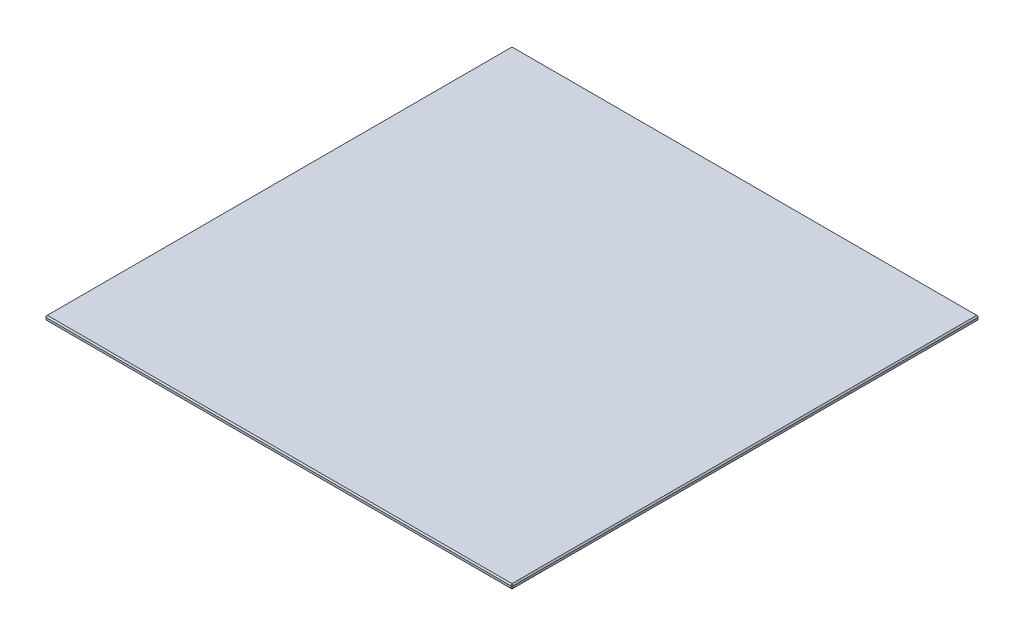
from build123d import *

# Parameters (mm, degrees)
SKETCH1_W           = 300
SKETCH1_H           = 300
BOSS_EXTRUDE1_DEPTH = 3
CHAMFER1_SIZE       = 0.8


with BuildPart() as part:
    # Sketch1 → Boss-Extrude1 (new body)
    with BuildSketch(Plane(origin=(0, 0, 0), x_dir=(1, 0, 0), z_dir=(0, 1, 0))):
        Rectangle(SKETCH1_W, SKETCH1_H)
    extrude(amount=BOSS_EXTRUDE1_DEPTH)

    # Chamfer1
    chamfer1_edges = [part.edges().sort_by_distance(p)[0] for p in [
        (150, 3, 0),
        (0, 3, -150),
        (-150, 3, 0),
        (0, 0, -150),
        (150, 0, 0),
        (0, 0, 150),
        (-150, 0, 0),
        (0, 3, 150),
        (-150, 1.5, -150),
        (150, 1.5, -150),
        (150, 1.5, 150),
        (-150, 1.5, 150),
    ]]
    chamfer(chamfer1_edges, length=CHAMFER1_SIZE)


solid = part.part
